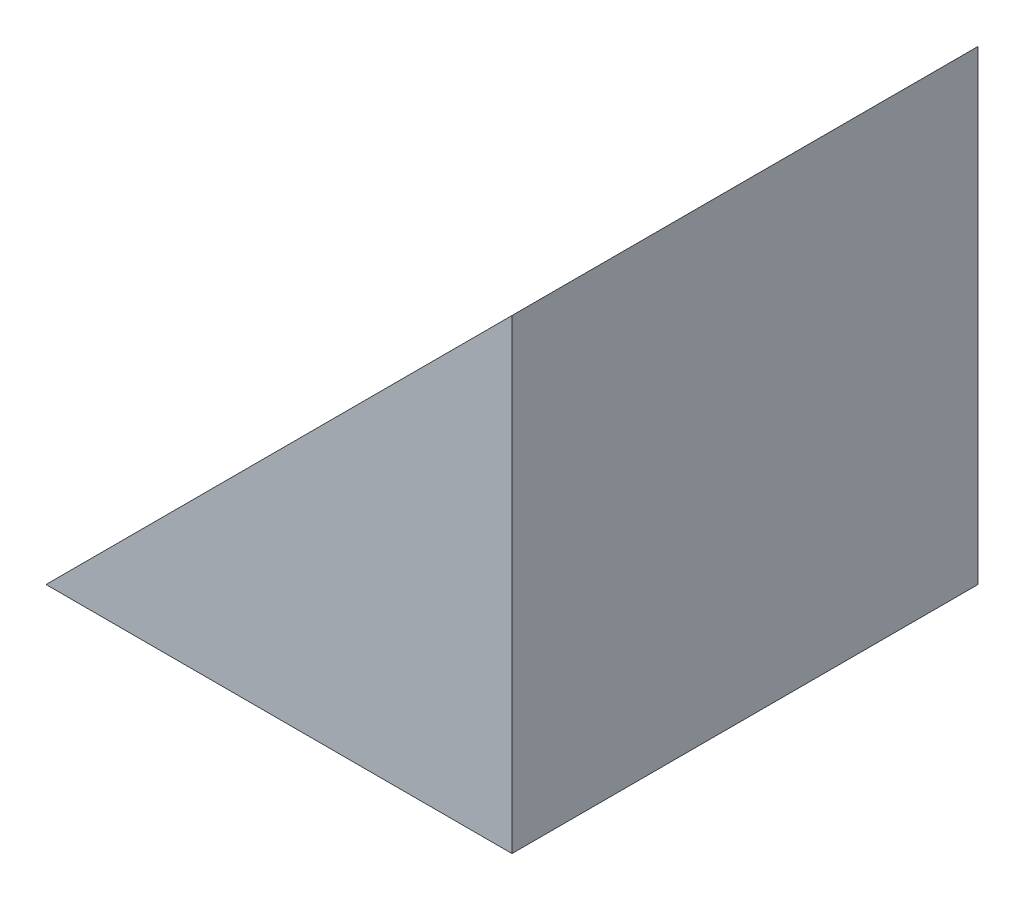
from build123d import *

# Parameters (mm, degrees)
EXTRUDE_1_DEPTH = 30


with BuildPart() as part:
    # 草图1 → 凸台-拉伸1 (new body)
    with BuildSketch(Plane.XY):
        Polygon((104.828438227, 79.667442144), (104.828438227, 109.667442144), (74.828438227, 79.667442144), align=None)
    extrude(amount=EXTRUDE_1_DEPTH)


solid = part.part
